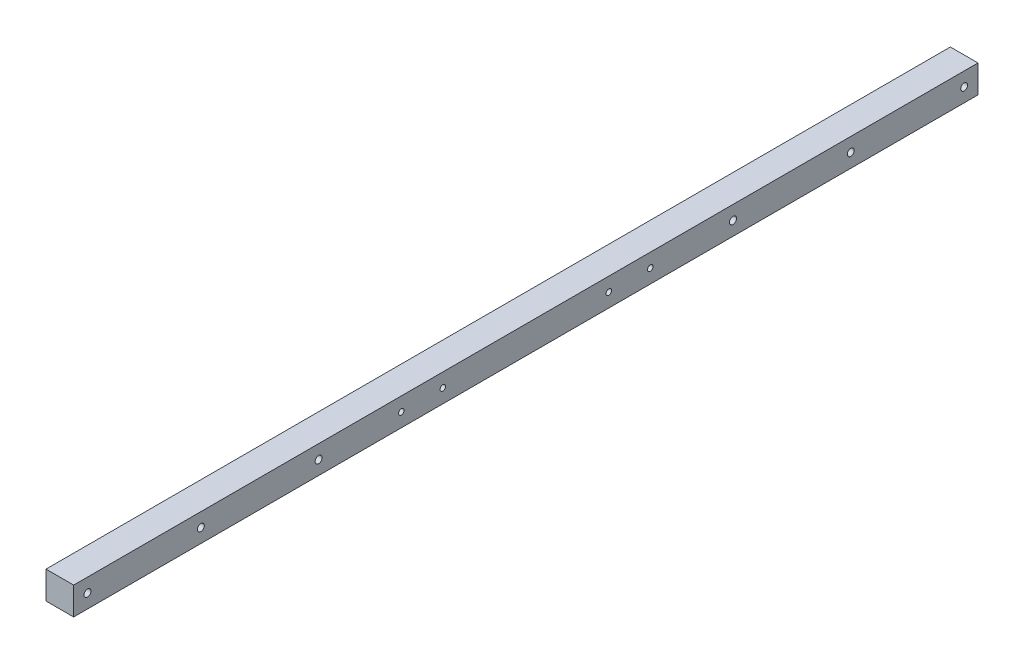
from build123d import *

# Parameters (mm, degrees)
SKETCH1_W                   = 25.4
SKETCH1_H                   = 25.4
BOSS_EXTRUDE1_DEPTH         = 830.58
SKETCH2_R                   = 3.175
CUT_EXTRUDE4_DEPTH          = 26.4
F_1_4_20_TAPPED_HOLE1_D     = 5.1054
F_1_4_20_TAPPED_HOLE1_DEPTH = 19.05
F_1_4_20_TAPPED_HOLE1_TIP   = 1.533816902
SKETCH7_R                   = 3.25
CUT_EXTRUDE5_DEPTH          = 26.4


with BuildPart() as part:
    # Sketch1 → Boss-Extrude1 (new body)
    with BuildSketch(Plane.XY):
        Rectangle(SKETCH1_W, SKETCH1_H)
    extrude(amount=BOSS_EXTRUDE1_DEPTH)

    # Sketch2 → Cut-Extrude4 (cut, through all)
    with BuildSketch(Plane(origin=(-12.7, 0, 0), x_dir=(0, 0, -1), z_dir=(1, 0, 0))):
        with Locations((-12.7, 0)):
            Circle(SKETCH2_R)
        with Locations((-116.84, 0)):
            Circle(SKETCH2_R)
    cut_extrude4 = extrude(amount=CUT_EXTRUDE4_DEPTH, mode=Mode.SUBTRACT)

    # Mirror1: Cut-Extrude4 across plane
    add(cut_extrude4.mirror(Plane(origin=(0, 0, 415.29), x_dir=(1, 0, 0), z_dir=(0, 0, -1))), mode=Mode.SUBTRACT)

    # 1/4-20 Tapped Hole1
    with Locations(Plane(origin=(12.7, 0, 0), x_dir=(0, 0, -1), z_dir=(1, 0, 0))):
        with Locations((-300.99, 0), (-529.59, 0), (-491.49, 0), (-339.09, 0)):
            Hole(F_1_4_20_TAPPED_HOLE1_D / 2, depth=F_1_4_20_TAPPED_HOLE1_DEPTH)
            with Locations((0, 0, -(F_1_4_20_TAPPED_HOLE1_DEPTH + F_1_4_20_TAPPED_HOLE1_TIP / 2))):  # 118° drill point
                Cone(0, F_1_4_20_TAPPED_HOLE1_D / 2, F_1_4_20_TAPPED_HOLE1_TIP, mode=Mode.SUBTRACT)

    # Sketch7 → Cut-Extrude5 (cut, through all)
    with BuildSketch(Plane.ZY.offset(12.7)):
        with Locations((605.58, 0)):
            Circle(SKETCH7_R)
        with Locations((225, 0)):
            Circle(SKETCH7_R)
    extrude(amount=-CUT_EXTRUDE5_DEPTH, mode=Mode.SUBTRACT)


solid = part.part
